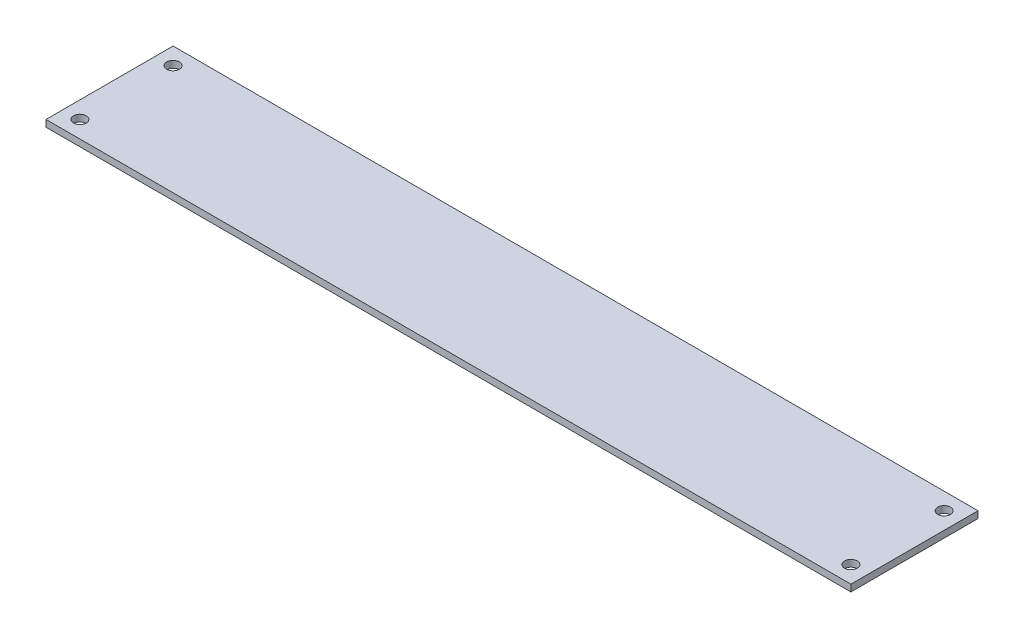
from build123d import *

# Parameters (mm, degrees)
SKETCH2_W               = 190
SKETCH2_H               = 30
BOSS_EXTRUDE1_DEPTH     = 1.6
SKETCH4_R               = 1.5
CUT_EXTRUDE2_DEPTH      = 1.6
MIRROR2_COPY_1_SKETCH_R = 1.5
MIRROR2_COPY_1_DEPTH    = 1.6


with BuildPart() as part:
    # Sketch2 → Boss-Extrude1 (new body)
    with BuildSketch(Plane(origin=(0, 0, 0), x_dir=(1, 0, 0), z_dir=(0, 1, 0))):
        Rectangle(SKETCH2_W, SKETCH2_H)
    extrude(amount=BOSS_EXTRUDE1_DEPTH)

    # Sketch4 → Cut-Extrude2 (cut)
    with BuildSketch(Plane(origin=(0, 1.6, 0), x_dir=(1, 0, 0), z_dir=(0, 1, 0))):
        with Locations((91, 11)):
            Circle(SKETCH4_R)
    cut_extrude2 = extrude(amount=-CUT_EXTRUDE2_DEPTH, mode=Mode.SUBTRACT)

    # Mirror1: Cut-Extrude2 across plane
    add(cut_extrude2.mirror(Plane.XY), mode=Mode.SUBTRACT)

    # Mirror2: Cut-Extrude2 across plane
    add(cut_extrude2.mirror(Plane(origin=(0, 0, 0), x_dir=(0, 0, 1), z_dir=(1, 0, 0))), mode=Mode.SUBTRACT)

    # Mirror2 copy 1 sketch → Mirror2 copy 1 (cut)
    with BuildSketch(Plane(origin=(0, 1.6, 0), x_dir=(-1, 0, 0), z_dir=(0, 1, 0))):
        with Locations((91, 11)):
            Circle(MIRROR2_COPY_1_SKETCH_R)
    extrude(amount=-MIRROR2_COPY_1_DEPTH, mode=Mode.SUBTRACT)


solid = part.part
